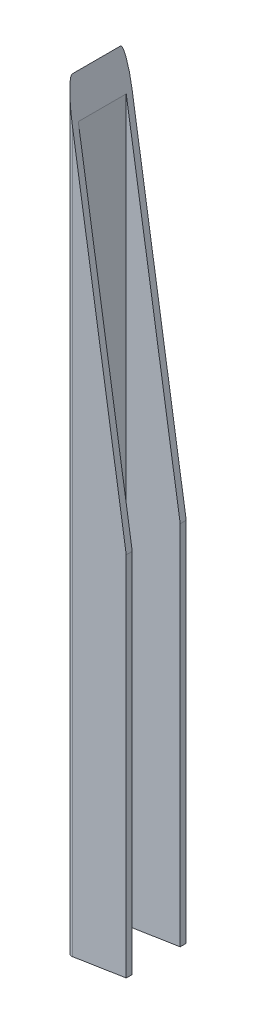
from build123d import *

# Parameters (mm, degrees)
SKETCH_1_W          = 74
SKETCH_1_H          = 24
EXTRUDE_1_DEPTH     = 380
SKETCH_2_W          = 51.146480438
SKETCH_2_H          = 42.897874587
CUT_EXTRUDE_1_DEPTH = 381
SKETCH_3_OUTSIDE_W  = 108.472
SKETCH_3_OUTSIDE_H  = 458.472
CUT_EXTRUDE_2_DEPTH = 31


with BuildPart() as part:
    # Эскиз1 → Вытянуть-Тонкостенный1 (new body)
    with BuildSketch(Plane(origin=(0, 0, 0), x_dir=(1, 0, 0), z_dir=(0, 1, 0))):
        with BuildLine():
            Line((40, 12), (40, -12))
            ThreePointArc((40, -12), (39.121320344, -14.121320344), (37, -15))
            Line((37, -15), (-37, -15))
            ThreePointArc((-37, -15), (-39.121320344, -14.121320344), (-40, -12))
            Line((-40, -12), (-40, 12))
            ThreePointArc((-40, 12), (-39.121320344, 14.121320344), (-37, 15))
            Line((-37, 15), (37, 15))
            ThreePointArc((37, 15), (39.121320344, 14.121320344), (40, 12))
        make_face()
        Rectangle(SKETCH_1_W, SKETCH_1_H, mode=Mode.SUBTRACT)
    extrude(amount=EXTRUDE_1_DEPTH)

    # Эскиз2 → Вырез-Вытянуть1 (cut, through all)
    with BuildSketch(Plane(origin=(0, 380, 0), x_dir=(1, 0, 0), z_dir=(0, 1, 0))):
        with Locations((15.573240219, -0.476163575)):
            Rectangle(SKETCH_2_W, SKETCH_2_H)
    extrude(amount=-CUT_EXTRUDE_1_DEPTH, mode=Mode.SUBTRACT)

    # Эскиз3 outside → Вырез-Вытянуть2 (cut, through all)
    with BuildSketch(Plane.XY.offset(15)):
        with Locations((-25, 190)):
            Rectangle(SKETCH_3_OUTSIDE_W, SKETCH_3_OUTSIDE_H)
        Polygon((-40, 380), (-10, 188.075345928), (-10, 4.689340222), (-40, 0), align=None, mode=Mode.SUBTRACT)
    extrude(amount=-CUT_EXTRUDE_2_DEPTH, mode=Mode.SUBTRACT)


solid = part.part
